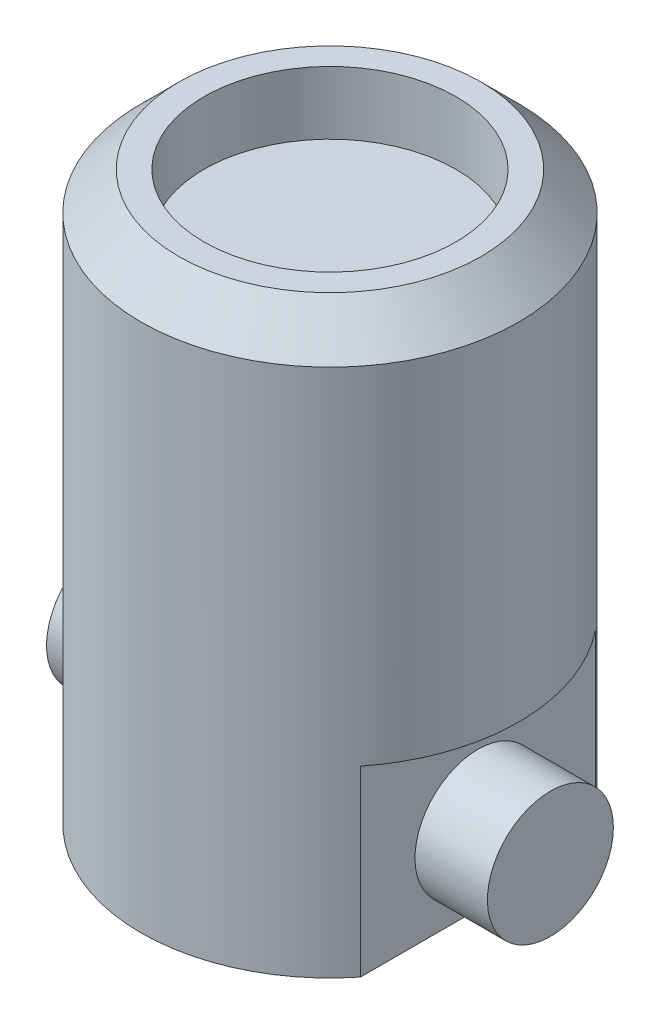
from build123d import *

# Parameters (mm, degrees)
SKETCH1_R           = 30
BOSS_EXTRUDE1_DEPTH = 90
SKETCH8_W           = 6.5
SKETCH8_H           = 29
CUT_EXTRUDE5_DEPTH  = 20
SKETCH5_R           = 10
BOSS_EXTRUDE3_DEPTH = 35
SKETCH7_R           = 20
CUT_EXTRUDE4_DEPTH  = 10
CHAMFER1_SIZE       = 6


with BuildPart() as part:
    # Sketch1 → Boss-Extrude1 (new body)
    with BuildSketch(Plane(origin=(0, 0, 0), x_dir=(1, 0, 0), z_dir=(0, 1, 0))):
        Circle(SKETCH1_R)
    extrude(amount=BOSS_EXTRUDE1_DEPTH)

    # Sketch8 → Cut-Extrude5 (cut, symmetric)
    with BuildSketch(Plane.XY):
        with Locations((-26.75, 14.5)):
            Rectangle(SKETCH8_W, SKETCH8_H)
        with Locations((26.75, 14.5)):
            Rectangle(SKETCH8_W, SKETCH8_H)
    extrude(amount=CUT_EXTRUDE5_DEPTH, both=True, mode=Mode.SUBTRACT)

    # Sketch5 → Boss-Extrude3 (add, symmetric)
    with BuildSketch(Plane(origin=(0, 0, 0), x_dir=(0, 0, -1), z_dir=(1, 0, 0))):
        with Locations((0, 12)):
            Circle(SKETCH5_R)
    extrude(amount=BOSS_EXTRUDE3_DEPTH, both=True)

    # Sketch7 → Cut-Extrude4 (cut)
    with BuildSketch(Plane(origin=(0, 90, 0), x_dir=(1, 0, 0), z_dir=(0, 1, 0))):
        Circle(SKETCH7_R)
    extrude(amount=-CUT_EXTRUDE4_DEPTH, mode=Mode.SUBTRACT)

    # Chamfer1
    chamfer1_edges = [part.edges().sort_by_distance(p)[0] for p in [
        (-30, 90, 0),
    ]]
    chamfer(chamfer1_edges, length=CHAMFER1_SIZE)


solid = part.part
